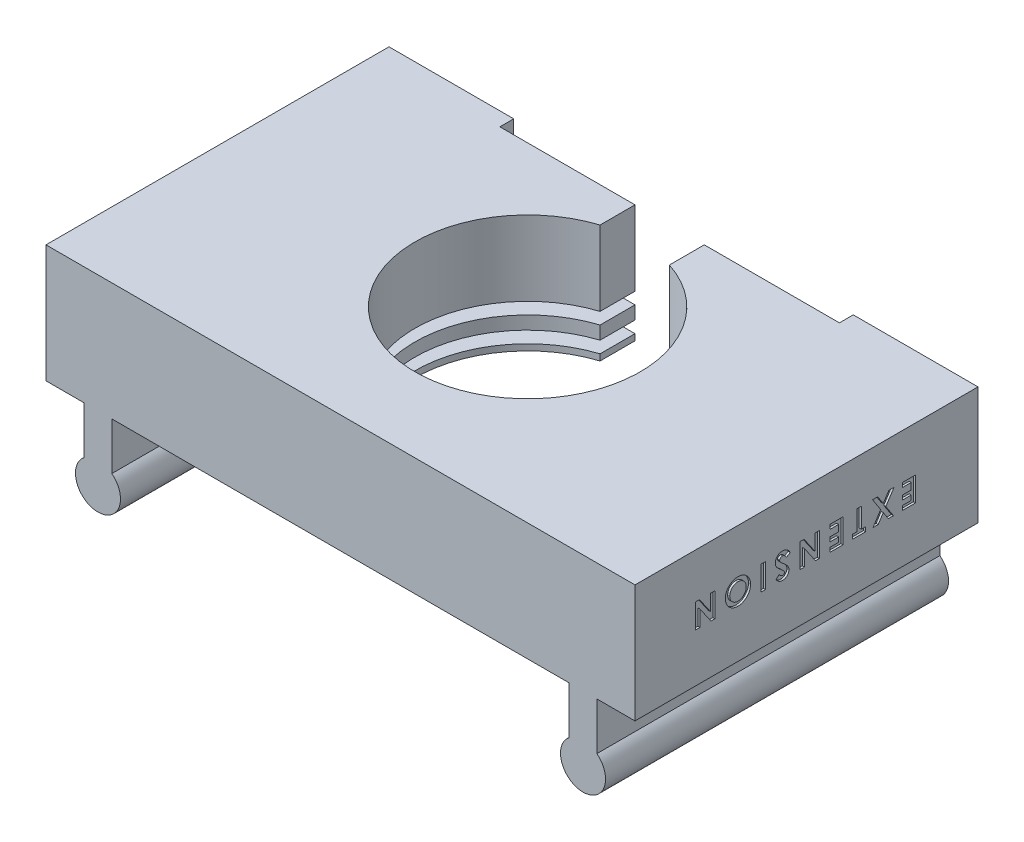
from build123d import *

# Parameters (mm, degrees)
ESQUISSE1_W             = 85
ESQUISSE1_H             = 17
BOSS_EXTRU_1_DEPTH      = 49.5
ESQUISSE2_W             = 49
ESQUISSE2_H             = 17
ENL_V_MAT_EXTRU_1_DEPTH = 2
ESQUISSE3_W             = 42
ESQUISSE3_H             = 1.7
ENL_V_MAT_EXTRU_2_DEPTH = 45
ESQUISSE4_R             = 16.25
ENL_V_MAT_EXTRU_3_DEPTH = 18
ESQUISSE5_W             = 10
ESQUISSE5_H             = 5.038353904
ENL_V_MAT_EXTRU_4_DEPTH = 18
BOSS_EXTRU_2_DEPTH      = 49.5
ESQUISSE9_W             = 0.628205128
ESQUISSE9_H             = 3.5
ENL_V_MAT_EXTRU_6_DEPTH = 0.3


with BuildPart() as part:
    # Esquisse1 → Boss.-Extru.1 (new body)
    with BuildSketch(Plane.XY):
        Rectangle(ESQUISSE1_W, ESQUISSE1_H)
    extrude(amount=BOSS_EXTRU_1_DEPTH)

    # Esquisse2 → Enlèv. mat.-Extru.1 (cut)
    with BuildSketch(Plane(origin=(0, 0, 0), x_dir=(-1, 0, 0), z_dir=(0, 0, -1))):
        Rectangle(ESQUISSE2_W, ESQUISSE2_H)
    extrude(amount=-ENL_V_MAT_EXTRU_1_DEPTH, mode=Mode.SUBTRACT)

    # Esquisse3 → Enlèv. mat.-Extru.2 (cut)
    with BuildSketch(Plane(origin=(0, 0, 2), x_dir=(-1, 0, 0), z_dir=(0, 0, -1))):
        with Locations((0, -6.75)):
            Rectangle(ESQUISSE3_W, ESQUISSE3_H)
        with Locations((0, -3.15)):
            Rectangle(ESQUISSE3_W, ESQUISSE3_H)
    extrude(amount=-ENL_V_MAT_EXTRU_2_DEPTH, mode=Mode.SUBTRACT)

    # Esquisse4 → Enlèv. mat.-Extru.3 (cut, through all)
    with BuildSketch(Plane.XZ.offset(8.5)):
        with Locations((0, 22.5)):
            Circle(ESQUISSE4_R)
    extrude(amount=-ENL_V_MAT_EXTRU_3_DEPTH, mode=Mode.SUBTRACT)

    # Esquisse5 → Enlèv. mat.-Extru.4 (cut, through all)
    with BuildSketch(Plane.XZ.offset(8.5)):
        with Locations((0, 4.519176952)):
            Rectangle(ESQUISSE5_W, ESQUISSE5_H)
    extrude(amount=-ENL_V_MAT_EXTRU_4_DEPTH, mode=Mode.SUBTRACT)

    # Esquisse7 → Boss.-Extru.2 (add)
    with BuildSketch(Plane(origin=(0, 0, 0), x_dir=(-1, 0, 0), z_dir=(0, 0, -1))):
        with BuildLine():
            Line((33, -8.5), (33, -15.34))
            ThreePointArc((33, -15.34), (35, -21.151737691), (37, -15.34))
            Line((37, -15.34), (37, -8.5))
            Line((37, -8.5), (33, -8.5))
        make_face()
        with BuildLine():
            Line((-33, -8.5), (-37, -8.5))
            Line((-37, -8.5), (-37, -15.34))
            ThreePointArc((-37, -15.34), (-35, -21.151737691), (-33, -15.34))
            Line((-33, -15.34), (-33, -8.5))
        make_face()
    extrude(amount=-BOSS_EXTRU_2_DEPTH)

    # Esquisse9 → Enlèv. mat.-Extru.6 (cut)
    with BuildSketch(Plane(origin=(42.5, 0, 0), x_dir=(0, 0, -1), z_dir=(1, 0, 0))):
        Polygon((-9.013461538, -1.5), (-10.898076923, -1.5), (-10.898076923, -0.871794872), (-9.641666667, -0.871794872), (-9.641666667, -0.198717949), (-10.898076923, -0.198717949), (-10.898076923, 0.429487179), (-9.641666667, 0.429487179), (-9.641666667, 1.371794872), (-10.898076923, 1.371794872), (-10.898076923, 2), (-9.013461538, 2), align=None)
        Polygon((-12.200901442, -1.5), (-12.941286058, -1.5), (-13.67255609, -0.376101763), (-14.405228365, -1.5), (-15.146314103, -1.5), (-14.042748397, 0.192508013), (-15.219230769, 2), (-14.478846154, 2), (-13.67255609, 0.760416667), (-12.86416266, 2), (-12.123076923, 2), (-13.302363782, 0.191806891), align=None)
        Polygon((-16.219871795, -1.5), (-18.104487179, -1.5), (-18.104487179, -0.871794872), (-17.476282051, -0.871794872), (-17.476282051, 2), (-16.848076923, 2), (-16.848076923, -0.871794872), (-16.219871795, -0.871794872), align=None)
        Polygon((-19.486538462, -1.5), (-21.371153846, -1.5), (-21.371153846, -0.871794872), (-20.11474359, -0.871794872), (-20.11474359, -0.198717949), (-21.371153846, -0.198717949), (-21.371153846, 0.429487179), (-20.11474359, 0.429487179), (-20.11474359, 1.371794872), (-21.371153846, 1.371794872), (-21.371153846, 2), (-19.486538462, 2), align=None)
        Polygon((-22.887820513, -1.5), (-23.453625801, -1.5), (-25.041666667, 0.803185096), (-25.041666667, -1.5), (-25.669871795, -1.5), (-25.669871795, 2), (-25.099859776, 2), (-23.516025641, -0.296173878), (-23.516025641, 2), (-22.887820513, 2), align=None)
        with BuildLine():
            Line((-29.160897436, -1.032351763), (-28.691145833, -0.602564103))
            add(Edge.make_bspline(
                [(-28.691145833, -0.602564103), (-28.671027561, -0.63095355), (-28.632403283, -0.68545733), (-28.569734427, -0.758359505), (-28.507439973, -0.820958469), (-28.444246248, -0.871464445), (-28.381241248, -0.912123347), (-28.317086399, -0.940167431), (-28.252519759, -0.95820275), (-28.209118161, -0.960437647), (-28.187740385, -0.961538462)],
                knots=[0, 0, 0, 0, 0.000104333, 0.000200305, 0.000288057, 0.000368866, 0.00044259, 0.000512284, 0.000578268, 0.000642316, 0.000642316, 0.000642316, 0.000642316], degree=3))
            add(Edge.make_bspline(
                [(-28.187740385, -0.961538462), (-28.167791641, -0.960859996), (-28.129275857, -0.959550059), (-28.074624503, -0.945874155), (-28.025511028, -0.923774631), (-27.983243684, -0.893247665), (-27.949240525, -0.856789609), (-27.922801038, -0.817978229), (-27.907437, -0.775661045), (-27.905463954, -0.74663918), (-27.904487179, -0.732271635)],
                knots=[0, 0, 0, 0, 5.9744e-05, 0.000115349, 0.000167746, 0.00022048, 0.000270574, 0.000316662, 0.00036057, 0.000403619, 0.000403619, 0.000403619, 0.000403619], degree=3))
            add(Edge.make_bspline(
                [(-27.904487179, -0.732271635), (-27.905105477, -0.717703647), (-27.906350641, -0.688365745), (-27.918377235, -0.645367395), (-27.936504746, -0.603353002), (-27.953826323, -0.577776842), (-27.962680288, -0.564703526)],
                knots=[0, 0, 0, 0, 4.3611e-05, 8.7826e-05, 0.000133031, 0.000180298, 0.000180298, 0.000180298, 0.000180298], degree=3))
            add(Edge.make_bspline(
                [(-27.962680288, -0.564703526), (-27.97076196, -0.554572005), (-27.989472392, -0.531115829), (-28.024065099, -0.493371591), (-28.069297145, -0.449061955), (-28.123256754, -0.395954284), (-28.187968929, -0.336111469), (-28.26204427, -0.267800829), (-28.347130868, -0.193342825), (-28.406742715, -0.14077887), (-28.438040865, -0.11318109)],
                knots=[0, 0, 0, 0, 3.8873e-05, 8.9997e-05, 0.000153455, 0.000228819, 0.000317115, 0.000417855, 0.000531103, 0.000656288, 0.000656288, 0.000656288, 0.000656288], degree=3))
            add(Edge.make_bspline(
                [(-28.438040865, -0.11318109), (-28.467489077, -0.087708176), (-28.523375665, -0.039365877), (-28.602790403, 0.029361089), (-28.673037142, 0.090915553), (-28.733477016, 0.145758452), (-28.78591611, 0.191631288), (-28.828035165, 0.23135622), (-28.861636788, 0.263195453), (-28.880718572, 0.282448406), (-28.888862179, 0.290665064)],
                knots=[0, 0, 0, 0, 0.00011681, 0.000221681, 0.000315075, 0.000396998, 0.000466519, 0.000524062, 0.000570675, 0.000605379, 0.000605379, 0.000605379, 0.000605379], degree=3))
            add(Edge.make_bspline(
                [(-28.888862179, 0.290665064), (-28.919776379, 0.324094588), (-28.979204328, 0.388357872), (-29.056288313, 0.488215347), (-29.120414735, 0.584942996), (-29.170074084, 0.681272249), (-29.20608924, 0.779193842), (-29.232306997, 0.880104872), (-29.248022012, 0.985448168), (-29.249761306, 1.057172142), (-29.250641026, 1.093449519)],
                knots=[0, 0, 0, 0, 0.000136539, 0.000262476, 0.000377989, 0.000484287, 0.00058678, 0.000690342, 0.000796635, 0.00090542, 0.00090542, 0.00090542, 0.00090542], degree=3))
            add(Edge.make_bspline(
                [(-29.250641026, 1.093449519), (-29.250014093, 1.128797664), (-29.248784029, 1.19815204), (-29.233734412, 1.299646549), (-29.212243866, 1.396763182), (-29.179129469, 1.488529029), (-29.138429267, 1.576031588), (-29.088825536, 1.659300286), (-29.028180017, 1.73639113), (-28.960820523, 1.809384245), (-28.885149236, 1.874903173), (-28.803778237, 1.932666563), (-28.716552563, 1.981437639), (-28.624136938, 2.021630033), (-28.52537232, 2.051457226), (-28.421818952, 2.074008321), (-28.312433494, 2.087605566), (-28.237792423, 2.089020647), (-28.199659455, 2.08974359)],
                knots=[0, 0, 0, 0, 0.000105953, 0.000207884, 0.000307206, 0.000403889, 0.000499869, 0.000596423, 0.000693889, 0.000793598, 0.000893984, 0.000993583, 0.001092463, 0.001193271, 0.001295284, 0.001401448, 0.001510935, 0.001625295, 0.001625295, 0.001625295, 0.001625295], degree=3))
            add(Edge.make_bspline(
                [(-28.199659455, 2.08974359), (-28.16972496, 2.089213111), (-28.110437493, 2.088162459), (-28.023060856, 2.079567137), (-27.938673024, 2.065738924), (-27.857442545, 2.045766284), (-27.778855587, 2.021036783), (-27.703764992, 1.988879594), (-27.631172385, 1.952514065), (-27.561319177, 1.910372306), (-27.494784205, 1.861428743), (-27.429650475, 1.807615149), (-27.368227041, 1.745980077), (-27.308167082, 1.678770457), (-27.251978998, 1.604038394), (-27.196701979, 1.524032643), (-27.145033938, 1.436840619), (-27.113103984, 1.375687022), (-27.096794872, 1.344451122)],
                knots=[0, 0, 0, 0, 8.9787e-05, 0.000177831, 0.000263126, 0.00034611, 0.000428593, 0.000509977, 0.000590874, 0.000672038, 0.000754359, 0.000838473, 0.000925234, 0.001015134, 0.001108667, 0.001205513, 0.001306757, 0.001412461, 0.001412461, 0.001412461, 0.001412461], degree=3))
            Line((-27.096794872, 1.344451122), (-27.649278846, 1.012820513))
            add(Edge.make_bspline(
                [(-27.649278846, 1.012820513), (-27.669677657, 1.048278527), (-27.70878392, 1.11625457), (-27.775053139, 1.207588999), (-27.842942571, 1.285801818), (-27.914021759, 1.349510612), (-27.987426406, 1.399567249), (-28.063511073, 1.435341194), (-28.142329217, 1.457485226), (-28.196016556, 1.460189524), (-28.222796474, 1.461538462)],
                knots=[0, 0, 0, 0, 0.000122646, 0.000235123, 0.000337949, 0.000432798, 0.000520693, 0.0006035, 0.000684117, 0.000764351, 0.000764351, 0.000764351, 0.000764351], degree=3))
            add(Edge.make_bspline(
                [(-28.222796474, 1.461538462), (-28.250040502, 1.460447314), (-28.302897882, 1.458330329), (-28.378469234, 1.438390474), (-28.448059568, 1.407785427), (-28.507889582, 1.363275092), (-28.558696766, 1.312520363), (-28.595120296, 1.255277022), (-28.618746967, 1.194084598), (-28.621201439, 1.151383871), (-28.622435897, 1.129907853)],
                knots=[0, 0, 0, 0, 8.1575e-05, 0.000158267, 0.000232945, 0.000308256, 0.000380645, 0.000447163, 0.000510598, 0.000574784, 0.000574784, 0.000574784, 0.000574784], degree=3))
            add(Edge.make_bspline(
                [(-28.622435897, 1.129907853), (-28.621280409, 1.10993794), (-28.618933144, 1.069370973), (-28.60173801, 1.009019401), (-28.5746312, 0.948960471), (-28.543522951, 0.89917714), (-28.511090926, 0.857680663), (-28.479301329, 0.822266476), (-28.441625158, 0.782321373), (-28.397102404, 0.738934614), (-28.346599026, 0.69127201), (-28.289949688, 0.639446883), (-28.226544328, 0.583881685), (-28.181727494, 0.546032766), (-28.158293269, 0.526241987)],
                knots=[0, 0, 0, 0, 5.9859e-05, 0.000121597, 0.000186877, 0.000257108, 0.000297078, 0.000344765, 0.000399815, 0.000461788, 0.000531224, 0.000608146, 0.000692108, 0.000784127, 0.000784127, 0.000784127, 0.000784127], degree=3))
            add(Edge.make_bspline(
                [(-28.158293269, 0.526241987), (-28.113745543, 0.488547865), (-28.028244972, 0.416201434), (-27.907400245, 0.309369191), (-27.798584134, 0.209450315), (-27.702522363, 0.115645445), (-27.618929579, 0.028553937), (-27.546885544, -0.051059631), (-27.487554451, -0.124756469), (-27.426031748, -0.212778618), (-27.365922264, -0.318526817), (-27.314837758, -0.44635181), (-27.281822688, -0.574016759), (-27.278109604, -0.65986803), (-27.276282051, -0.702123397)],
                knots=[0, 0, 0, 0, 0.000175062, 0.000335996, 0.000483855, 0.000618216, 0.000738713, 0.000845964, 0.000940241, 0.00102232, 0.001167987, 0.00130391, 0.001434509, 0.001561092, 0.001561092, 0.001561092, 0.001561092], degree=3))
            add(Edge.make_bspline(
                [(-27.276282051, -0.702123397), (-27.277042485, -0.73208793), (-27.27854062, -0.791121279), (-27.291864649, -0.877931395), (-27.311870527, -0.961656273), (-27.340620212, -1.042274728), (-27.379181412, -1.118878553), (-27.424729254, -1.192707598), (-27.478560698, -1.263536206), (-27.540257249, -1.329793188), (-27.607983082, -1.390700018), (-27.680219267, -1.444136117), (-27.756298405, -1.489321513), (-27.836451204, -1.526132122), (-27.920535833, -1.554857248), (-28.008629956, -1.575157759), (-28.100463608, -1.587263752), (-28.162930704, -1.588906679), (-28.194751603, -1.58974359)],
                knots=[0, 0, 0, 0, 8.9842e-05, 0.000176999, 0.000262874, 0.000347814, 0.0004331, 0.000519683, 0.000607745, 0.000699528, 0.000790884, 0.00088063, 0.000968648, 0.001055861, 0.001144771, 0.001234739, 0.001326661, 0.001422106, 0.001422106, 0.001422106, 0.001422106], degree=3))
            add(Edge.make_bspline(
                [(-28.194751603, -1.58974359), (-28.235987469, -1.588230986), (-28.318133701, -1.585217718), (-28.43962522, -1.561777842), (-28.558351484, -1.524527272), (-28.654319608, -1.480647774), (-28.730022714, -1.436786563), (-28.788183115, -1.397224011), (-28.847825983, -1.351792628), (-28.907856379, -1.299170325), (-28.970550671, -1.242399002), (-29.032742125, -1.177582647), (-29.097476175, -1.108042266), (-29.139386668, -1.058023924), (-29.160897436, -1.032351763)],
                knots=[0, 0, 0, 0, 0.000123638, 0.0002463, 0.000369811, 0.000496249, 0.000561908, 0.000632107, 0.000707131, 0.000786676, 0.000871524, 0.000960767, 0.001056037, 0.001156496, 0.001156496, 0.001156496, 0.001156496], degree=3))
        make_face()
        with Locations((-30.991666667, 0.25)):
            Rectangle(ESQUISSE9_W, ESQUISSE9_H)
        with BuildLine():
            add(Edge.make_bspline(
                [(-34.646754808, -1.58974359), (-34.707606901, -1.588168661), (-34.827742715, -1.585059395), (-35.004413887, -1.559121692), (-35.174689646, -1.516908566), (-35.3385944, -1.457985839), (-35.495569153, -1.381675624), (-35.646190671, -1.289020183), (-35.790046192, -1.179233296), (-35.925458503, -1.053881628), (-36.049628278, -0.916813501), (-36.15877492, -0.770679131), (-36.251426585, -0.616987295), (-36.326632165, -0.455708046), (-36.385362299, -0.287062919), (-36.426179051, -0.110987913), (-36.452496726, 0.072291501), (-36.455516529, 0.197090352), (-36.457051282, 0.260516827)],
                knots=[0, 0, 0, 0, 0.000182486, 0.000360268, 0.000534396, 0.00070805, 0.000881771, 0.001057093, 0.001237707, 0.001423768, 0.00160992, 0.001791792, 0.00197011, 0.002147329, 0.002324714, 0.002504809, 0.00268884, 0.00287903, 0.00287903, 0.00287903, 0.00287903], degree=3))
            add(Edge.make_bspline(
                [(-36.457051282, 0.260516827), (-36.45541632, 0.323228512), (-36.452194575, 0.446803899), (-36.427256637, 0.62839604), (-36.385730477, 0.802578596), (-36.32813259, 0.969411115), (-36.254241994, 1.128896333), (-36.1630053, 1.280516738), (-36.055021934, 1.424583864), (-35.932497691, 1.5602151), (-35.798441306, 1.684128709), (-35.655606652, 1.792909636), (-35.505320736, 1.884404437), (-35.348543758, 1.960347086), (-35.183796706, 2.017415825), (-35.012906117, 2.060131946), (-34.834442443, 2.084832759), (-34.713201994, 2.088090183), (-34.65166266, 2.08974359)],
                knots=[0, 0, 0, 0, 0.000188089, 0.000370635, 0.000548684, 0.000724515, 0.000899235, 0.001075028, 0.001254375, 0.001438546, 0.001622627, 0.001801275, 0.001976231, 0.002149648, 0.002322831, 0.00249832, 0.002677393, 0.00286198, 0.00286198, 0.00286198, 0.00286198], degree=3))
            add(Edge.make_bspline(
                [(-34.65166266, 2.08974359), (-34.587294915, 2.08827779), (-34.460821093, 2.085397695), (-34.275680143, 2.058240346), (-34.098551922, 2.016835351), (-33.929921764, 1.956890881), (-33.769920762, 1.879001388), (-33.617831377, 1.784955769), (-33.474797459, 1.672937404), (-33.341295779, 1.546324957), (-33.220357024, 1.407747241), (-33.113601168, 1.261361497), (-33.023551159, 1.108274754), (-32.950202373, 0.948418287), (-32.892377197, 0.782784804), (-32.85158809, 0.61036575), (-32.827492995, 0.431574594), (-32.824136688, 0.310136069), (-32.822435897, 0.248597756)],
                knots=[0, 0, 0, 0, 0.000192992, 0.000379203, 0.000560143, 0.000737993, 0.000914849, 0.001093067, 0.001273424, 0.001458907, 0.001644244, 0.001824454, 0.002001698, 0.002176124, 0.002351292, 0.002527132, 0.002706806, 0.002891392, 0.002891392, 0.002891392, 0.002891392], degree=3))
            add(Edge.make_bspline(
                [(-32.822435897, 0.248597756), (-32.822977068, 0.207199796), (-32.824052557, 0.124928068), (-32.836723497, 0.00297392), (-32.85551605, -0.116425047), (-32.881242604, -0.233493361), (-32.915904827, -0.347929328), (-32.958033943, -0.460021607), (-33.007127642, -0.569769578), (-33.063741214, -0.676180726), (-33.127782459, -0.777981899), (-33.19616123, -0.876062234), (-33.271496578, -0.967846929), (-33.352233548, -1.054332991), (-33.43868838, -1.135125073), (-33.531011644, -1.210499044), (-33.629058027, -1.28026266), (-33.731767024, -1.344992407), (-33.838787293, -1.40168561), (-33.94757262, -1.453073846), (-34.059167332, -1.494739415), (-34.172761175, -1.529248151), (-34.288092987, -1.556942813), (-34.40605323, -1.575357402), (-34.525646348, -1.588128444), (-34.606289516, -1.58920393), (-34.646754808, -1.58974359)],
                knots=[0, 0, 0, 0, 0.000124148, 0.000246724, 0.000367409, 0.000486651, 0.000605986, 0.000725794, 0.000845675, 0.000966433, 0.001087053, 0.001206295, 0.001324886, 0.001442946, 0.001561005, 0.001679596, 0.001800222, 0.001921807, 0.002043514, 0.00216334, 0.002282492, 0.002400484, 0.002519357, 0.002637965, 0.002758448, 0.002879792, 0.002879792, 0.002879792, 0.002879792], degree=3))
        make_face()
        with BuildLine():
            add(Edge.make_bspline(
                [(-34.636939103, -0.961538462), (-34.595985858, -0.960439593), (-34.515160542, -0.958270865), (-34.396604489, -0.941748135), (-34.282786621, -0.915359354), (-34.174337265, -0.877135893), (-34.070788651, -0.828485819), (-33.971948768, -0.769585006), (-33.87921839, -0.69838629), (-33.791237427, -0.618797241), (-33.71202913, -0.529750419), (-33.640810142, -0.435361289), (-33.5832267, -0.333358687), (-33.53371316, -0.227102306), (-33.497139753, -0.113905032), (-33.469292918, 0.004395951), (-33.454125691, 0.129015087), (-33.451819129, 0.213737994), (-33.450641026, 0.257011218)],
                knots=[0, 0, 0, 0, 0.000122824, 0.000242406, 0.000358388, 0.000472807, 0.000586661, 0.000701131, 0.000817238, 0.000936842, 0.001056496, 0.001174287, 0.001290818, 0.001407217, 0.001525391, 0.001646995, 0.001771353, 0.001901181, 0.001901181, 0.001901181, 0.001901181], degree=3))
            add(Edge.make_bspline(
                [(-33.450641026, 0.257011218), (-33.452073068, 0.304981039), (-33.454879634, 0.398993941), (-33.474339691, 0.536210947), (-33.508437502, 0.665649698), (-33.555019221, 0.78774321), (-33.616939614, 0.9012076), (-33.690997801, 1.007418434), (-33.779048038, 1.105716727), (-33.846762021, 1.163155183), (-33.881129808, 1.192307692)],
                knots=[0, 0, 0, 0, 0.000143901, 0.000282022, 0.000414667, 0.00054474, 0.000673047, 0.000801422, 0.000932488, 0.00106757, 0.00106757, 0.00106757, 0.00106757], degree=3))
            add(Edge.make_bspline(
                [(-33.881129808, 1.192307692), (-33.909291086, 1.213841032), (-33.964979165, 1.256422561), (-34.053869463, 1.310999526), (-34.145408966, 1.357777429), (-34.240288455, 1.395573422), (-34.33830755, 1.425303114), (-34.439452809, 1.446122329), (-34.543580917, 1.459188186), (-34.613997224, 1.460749804), (-34.649559295, 1.461538462)],
                knots=[0, 0, 0, 0, 0.000106293, 0.000210192, 0.000312412, 0.000414354, 0.000516162, 0.000619291, 0.000723822, 0.000830475, 0.000830475, 0.000830475, 0.000830475], degree=3))
            add(Edge.make_bspline(
                [(-34.649559295, 1.461538462), (-34.689807568, 1.460428703), (-34.768997311, 1.458245219), (-34.885357504, 1.441948345), (-34.996782394, 1.414247454), (-35.104304774, 1.376630647), (-35.206484836, 1.32621761), (-35.304916004, 1.266355995), (-35.398425147, 1.195178847), (-35.485872328, 1.113584088), (-35.566012995, 1.024533066), (-35.636915182, 0.929633395), (-35.695633882, 0.82888138), (-35.744612751, 0.723622851), (-35.782772745, 0.61301973), (-35.808887726, 0.497063674), (-35.825671324, 0.376222513), (-35.827774644, 0.293993782), (-35.828846154, 0.252103365)],
                knots=[0, 0, 0, 0, 0.000120723, 0.000237527, 0.000351629, 0.000464725, 0.000578551, 0.000692784, 0.000809874, 0.000930428, 0.001051072, 0.001168862, 0.001285141, 0.001400266, 0.001516671, 0.001635384, 0.001756356, 0.001881982, 0.001881982, 0.001881982, 0.001881982], degree=3))
            add(Edge.make_bspline(
                [(-35.828846154, 0.252103365), (-35.82774172, 0.210452112), (-35.825567811, 0.128467972), (-35.80917961, 0.007962039), (-35.781934783, -0.107356876), (-35.743429135, -0.217786038), (-35.69545911, -0.32390519), (-35.635200773, -0.42479331), (-35.563960253, -0.520363111), (-35.483039888, -0.610046419), (-35.394977531, -0.692465159), (-35.300429972, -0.763988235), (-35.202047282, -0.826139881), (-35.097570898, -0.874826882), (-34.989138626, -0.913615736), (-34.876088725, -0.942180398), (-34.757993034, -0.958154796), (-34.677650093, -0.960400519), (-34.636939103, -0.961538462)],
                knots=[0, 0, 0, 0, 0.000124926, 0.000245897, 0.000364088, 0.00047983, 0.000596229, 0.000712864, 0.000831635, 0.000953269, 0.001074815, 0.001192886, 0.001308453, 0.00142324, 0.001537892, 0.001653524, 0.001772411, 0.001894535, 0.001894535, 0.001894535, 0.001894535], degree=3))
        make_face(mode=Mode.SUBTRACT)
        Polygon((-37.973717949, -1.5), (-38.539523237, -1.5), (-40.127564103, 0.803185096), (-40.127564103, -1.5), (-40.755769231, -1.5), (-40.755769231, 2), (-40.185757212, 2), (-38.601923077, -0.296173878), (-38.601923077, 2), (-37.973717949, 2), align=None)
    extrude(amount=-ENL_V_MAT_EXTRU_6_DEPTH, mode=Mode.SUBTRACT)


solid = part.part
